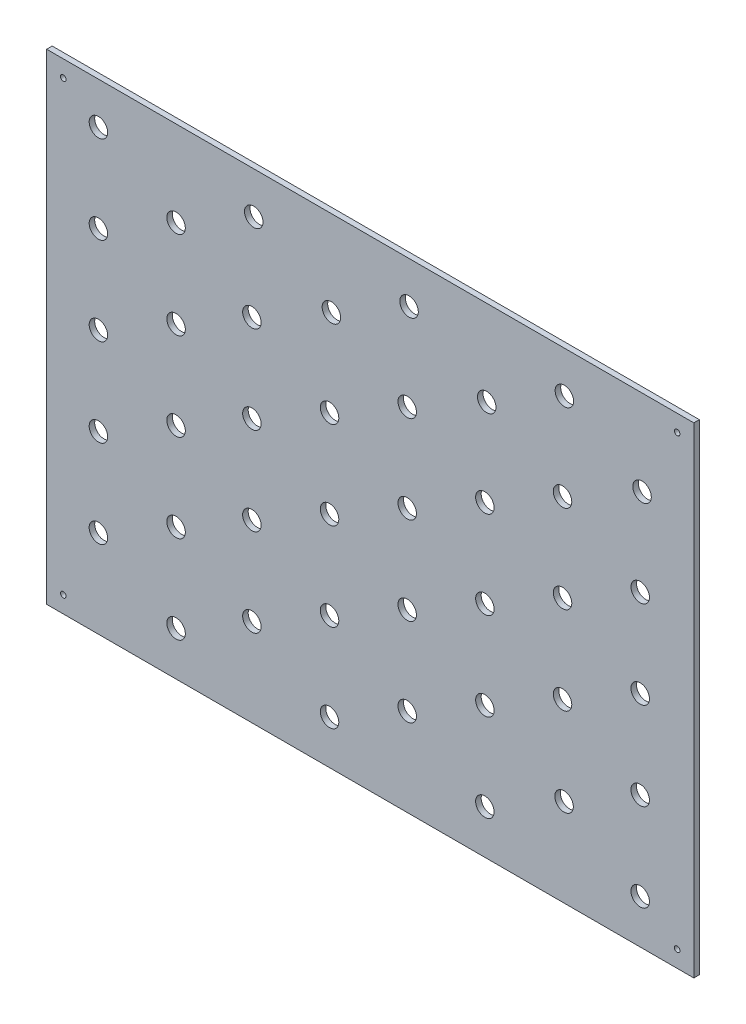
from build123d import *

# Parameters (mm, degrees)
CROQUIS2_W              = 350
CROQUIS2_H              = 260
CROQUIS2_R              = 5
CROQUIS2_R_2            = 1.5
SALIENTE_EXTRUIR1_DEPTH = 3


with BuildPart() as part:
    # Croquis2 → Saliente-Extruir1 (new body)
    with BuildSketch(Plane.XY):
        with Locations((101.967310491, -89.518527919)):
            Rectangle(CROQUIS2_W, CROQUIS2_H)
        with Locations((-45.032689509, 17.981472081)):
            Circle(CROQUIS2_R, mode=Mode.SUBTRACT)
        with Locations((-45.032689509, -29.518527919)):
            Circle(CROQUIS2_R, mode=Mode.SUBTRACT)
        with Locations((-45.032689509, -77.018527919)):
            Circle(CROQUIS2_R, mode=Mode.SUBTRACT)
        with Locations((-45.032689509, -124.518527919)):
            Circle(CROQUIS2_R, mode=Mode.SUBTRACT)
        with Locations((-45.032689509, -172.018527919)):
            Circle(CROQUIS2_R, mode=Mode.SUBTRACT)
        with Locations((-3.032689509, -5.768527919)):
            Circle(CROQUIS2_R, mode=Mode.SUBTRACT)
        with Locations((38.967310491, 17.981472081)):
            Circle(CROQUIS2_R, mode=Mode.SUBTRACT)
        with Locations((80.967310491, -5.768527919)):
            Circle(CROQUIS2_R, mode=Mode.SUBTRACT)
        with Locations((122.967310491, 17.981472081)):
            Circle(CROQUIS2_R, mode=Mode.SUBTRACT)
        with Locations((164.967310491, -5.768527919)):
            Circle(CROQUIS2_R, mode=Mode.SUBTRACT)
        with Locations((-3.032689509, -53.268527919)):
            Circle(CROQUIS2_R, mode=Mode.SUBTRACT)
        with Locations((-3.032689509, -100.768527919)):
            Circle(CROQUIS2_R, mode=Mode.SUBTRACT)
        with Locations((-3.032689509, -148.268527919)):
            Circle(CROQUIS2_R, mode=Mode.SUBTRACT)
        with Locations((-3.032689509, -195.768527919)):
            Circle(CROQUIS2_R, mode=Mode.SUBTRACT)
        with Locations((37.967310491, -29.518527919)):
            Circle(CROQUIS2_R, mode=Mode.SUBTRACT)
        with Locations((37.967310491, -77.018527919)):
            Circle(CROQUIS2_R, mode=Mode.SUBTRACT)
        with Locations((37.967310491, -124.518527919)):
            Circle(CROQUIS2_R, mode=Mode.SUBTRACT)
        with Locations((37.967310491, -172.018527919)):
            Circle(CROQUIS2_R, mode=Mode.SUBTRACT)
        with Locations((79.967310491, -53.268527919)):
            Circle(CROQUIS2_R, mode=Mode.SUBTRACT)
        with Locations((79.967310491, -100.768527919)):
            Circle(CROQUIS2_R, mode=Mode.SUBTRACT)
        with Locations((79.967310491, -148.268527919)):
            Circle(CROQUIS2_R, mode=Mode.SUBTRACT)
        with Locations((79.967310491, -195.768527919)):
            Circle(CROQUIS2_R, mode=Mode.SUBTRACT)
        with Locations((121.967310491, -29.518527919)):
            Circle(CROQUIS2_R, mode=Mode.SUBTRACT)
        with Locations((163.967310491, -53.268527919)):
            Circle(CROQUIS2_R, mode=Mode.SUBTRACT)
        with Locations((121.967310491, -77.018527919)):
            Circle(CROQUIS2_R, mode=Mode.SUBTRACT)
        with Locations((163.967310491, -100.768527919)):
            Circle(CROQUIS2_R, mode=Mode.SUBTRACT)
        with Locations((121.967310491, -124.518527919)):
            Circle(CROQUIS2_R, mode=Mode.SUBTRACT)
        with Locations((121.967310491, -172.018527919)):
            Circle(CROQUIS2_R, mode=Mode.SUBTRACT)
        with Locations((163.967310491, -148.268527919)):
            Circle(CROQUIS2_R, mode=Mode.SUBTRACT)
        with Locations((163.967310491, -195.768527919)):
            Circle(CROQUIS2_R, mode=Mode.SUBTRACT)
        with Locations((206.967310491, 18.071533546)):
            Circle(CROQUIS2_R, mode=Mode.SUBTRACT)
        with Locations((205.967310491, -29.518527919)):
            Circle(CROQUIS2_R, mode=Mode.SUBTRACT)
        with Locations((205.967310491, -77.018527919)):
            Circle(CROQUIS2_R, mode=Mode.SUBTRACT)
        with Locations((205.967310491, -124.518527919)):
            Circle(CROQUIS2_R, mode=Mode.SUBTRACT)
        with Locations((206.796228515, -171.928466454)):
            Circle(CROQUIS2_R, mode=Mode.SUBTRACT)
        with Locations((248.967310491, -5.768527919)):
            Circle(CROQUIS2_R, mode=Mode.SUBTRACT)
        with Locations((247.967310491, -53.268527919)):
            Circle(CROQUIS2_R, mode=Mode.SUBTRACT)
        with Locations((247.967310491, -100.768527919)):
            Circle(CROQUIS2_R, mode=Mode.SUBTRACT)
        with Locations((247.967310491, -148.268527919)):
            Circle(CROQUIS2_R, mode=Mode.SUBTRACT)
        with Locations((247.967310491, -195.768527919)):
            Circle(CROQUIS2_R, mode=Mode.SUBTRACT)
        with Locations((-64.032689509, -210.518527919)):
            Circle(CROQUIS2_R_2, mode=Mode.SUBTRACT)
        with Locations((267.967310491, -210.518527919)):
            Circle(CROQUIS2_R_2, mode=Mode.SUBTRACT)
        with Locations((267.967310491, 31.481472081)):
            Circle(CROQUIS2_R_2, mode=Mode.SUBTRACT)
        with Locations((-64.032689509, 31.481472081)):
            Circle(CROQUIS2_R_2, mode=Mode.SUBTRACT)
    extrude(amount=SALIENTE_EXTRUIR1_DEPTH)


solid = part.part
